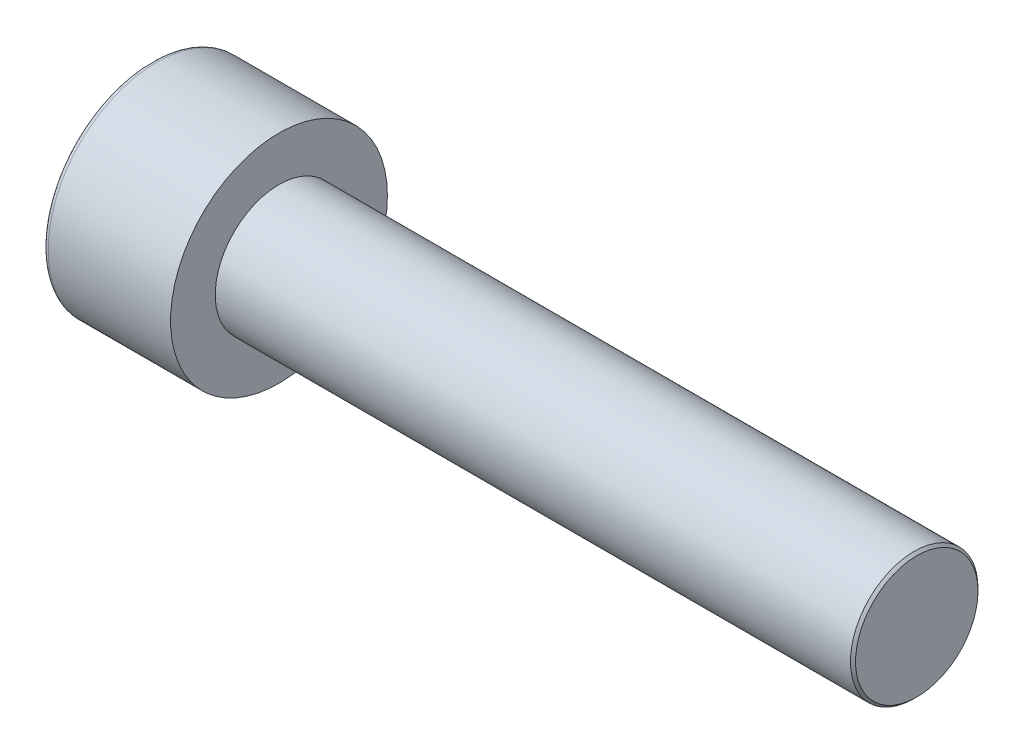
from build123d import *

# Parameters (mm, degrees)
SKETCH1_R           = 4.25
BASEHEAD_DEPTH      = 5
SKETCH2_R           = 2.5
BASEBODY_DEPTH      = 25
HEXAGONSOCKET_DEPTH = 2.5
TOPFILLET_R         = 0.2
CHAMFER1_SIZE       = 0.1


with BuildPart() as part:
    # Sketch1 → BaseHead (new body)
    with BuildSketch(Plane(origin=(0, 0, 0), x_dir=(0, 0, -1), z_dir=(1, 0, 0))):
        Circle(SKETCH1_R)
    extrude(amount=BASEHEAD_DEPTH)

    # Sketch2 → BaseBody (add)
    with BuildSketch(Plane(origin=(5, 0, 0), x_dir=(0, 0, -1), z_dir=(1, 0, 0))):
        Circle(SKETCH2_R)
    extrude(amount=BASEBODY_DEPTH)

    # Sketch3 → HexagonSocket (cut)
    with BuildSketch(Plane(origin=(0, 0, 0), x_dir=(0, 0, -1), z_dir=(1, 0, 0))):
        Polygon((2.309401077, 0), (1.154700538, 2), (-1.154700538, 2), (-2.309401077, 0), (-1.154700538, -2), (1.154700538, -2), align=None)
    extrude(amount=HEXAGONSOCKET_DEPTH, mode=Mode.SUBTRACT)

    # Sketch4 → Cut-Revolve1 (revolve, cut)
    with BuildSketch(Plane(origin=(-4.19613823, 0.75, 0), x_dir=(-1, 0, 0), z_dir=(0, 0, 1))):
        Polygon((-6.69613823, 2.75), (-7.850838768, 0.75), (-6.69613823, 0.75), align=None)
    revolve(axis=Axis((0.838992387, 0, 0), (-1, 0, 0)), mode=Mode.SUBTRACT)

    # TopFillet
    topfillet_edges = [part.edges().sort_by_distance(p)[0] for p in [
        (0, 0, 4.25),
    ]]
    fillet(topfillet_edges, radius=TOPFILLET_R)

    # Chamfer1
    chamfer1_edges = [part.edges().sort_by_distance(p)[0] for p in [
        (30, 0, 2.5),
    ]]
    chamfer(chamfer1_edges, length=CHAMFER1_SIZE)


solid = part.part
